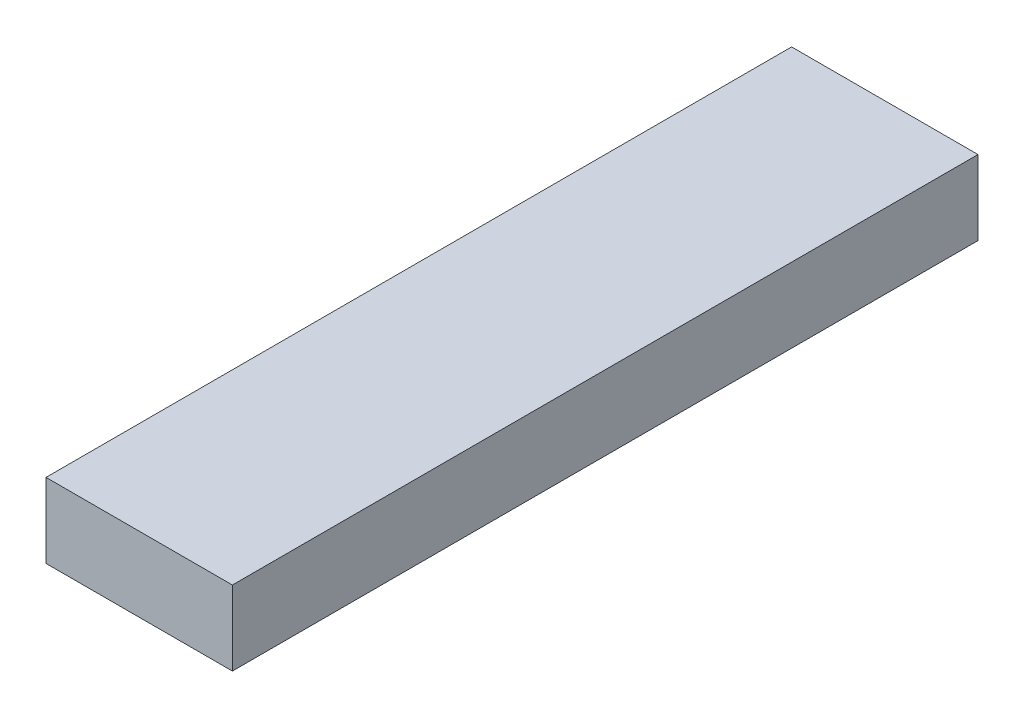
from build123d import *

# Parameters (mm, degrees)
CROQUIS1_W              = 0.5
CROQUIS1_H              = 0.2
SALIENTE_EXTRUIR1_DEPTH = 2


with BuildPart() as part:
    # Croquis1 → Saliente-Extruir1 (new body)
    with BuildSketch(Plane.XY):
        with Locations((0.25, 0.1)):
            Rectangle(CROQUIS1_W, CROQUIS1_H)
    extrude(amount=SALIENTE_EXTRUIR1_DEPTH)


solid = part.part
